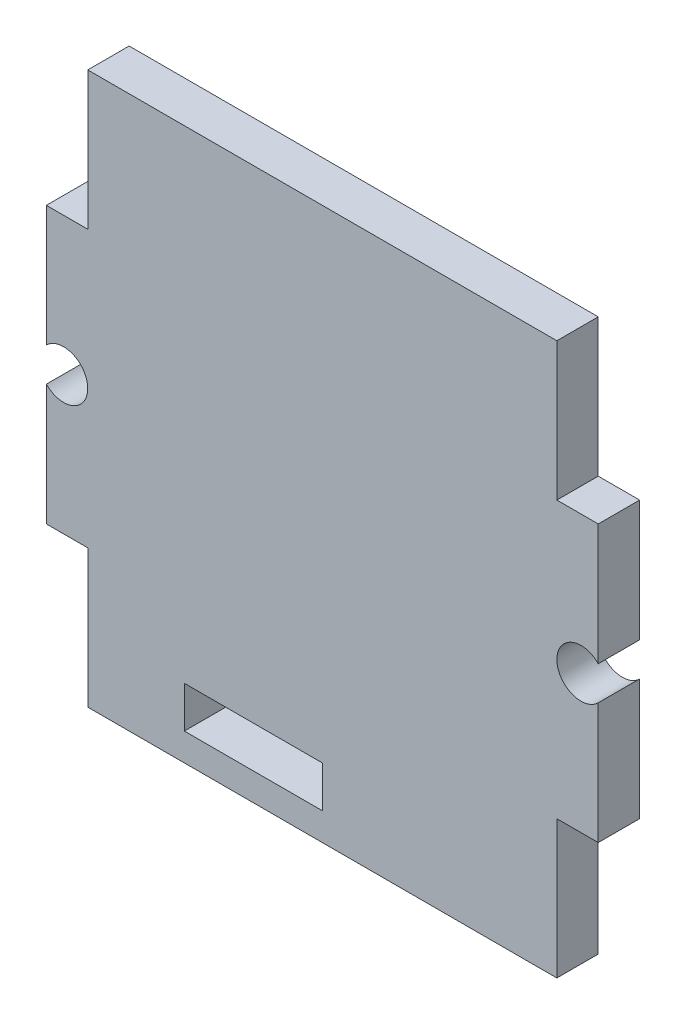
from build123d import *

# Parameters (mm, degrees)
SKETCH_1_W      = 10
SKETCH_1_H      = 3
EXTRUDE_1_DEPTH = 1.5


with BuildPart() as part:
    # 草图1 → 凸台-拉伸1 (new body, symmetric)
    with BuildSketch(Plane.XY):
        with BuildLine():
            Line((-17, 20), (17, 20))
            Line((17, 20), (17, 10))
            Line((17, 10), (20, 10))
            Line((20, 10), (20, 1.224744871))
            ThreePointArc((20, 1.224744871), (17, 0), (20, -1.224744871))
            Line((20, -1.224744871), (20, -10))
            Line((20, -10), (17, -10))
            Line((17, -10), (17, -20))
            Line((17, -20), (-17, -20))
            Line((-17, -20), (-17, -10))
            Line((-17, -10), (-20, -10))
            Line((-20, -10), (-20, -1.224744871))
            ThreePointArc((-20, -1.224744871), (-17, 0), (-20, 1.224744871))
            Line((-20, 1.224744871), (-20, 10))
            Line((-20, 10), (-17, 10))
            Line((-17, 10), (-17, 20))
        make_face()
        with Locations((-5, -16.5)):
            Rectangle(SKETCH_1_W, SKETCH_1_H, mode=Mode.SUBTRACT)
    extrude(amount=EXTRUDE_1_DEPTH, both=True)


solid = part.part
